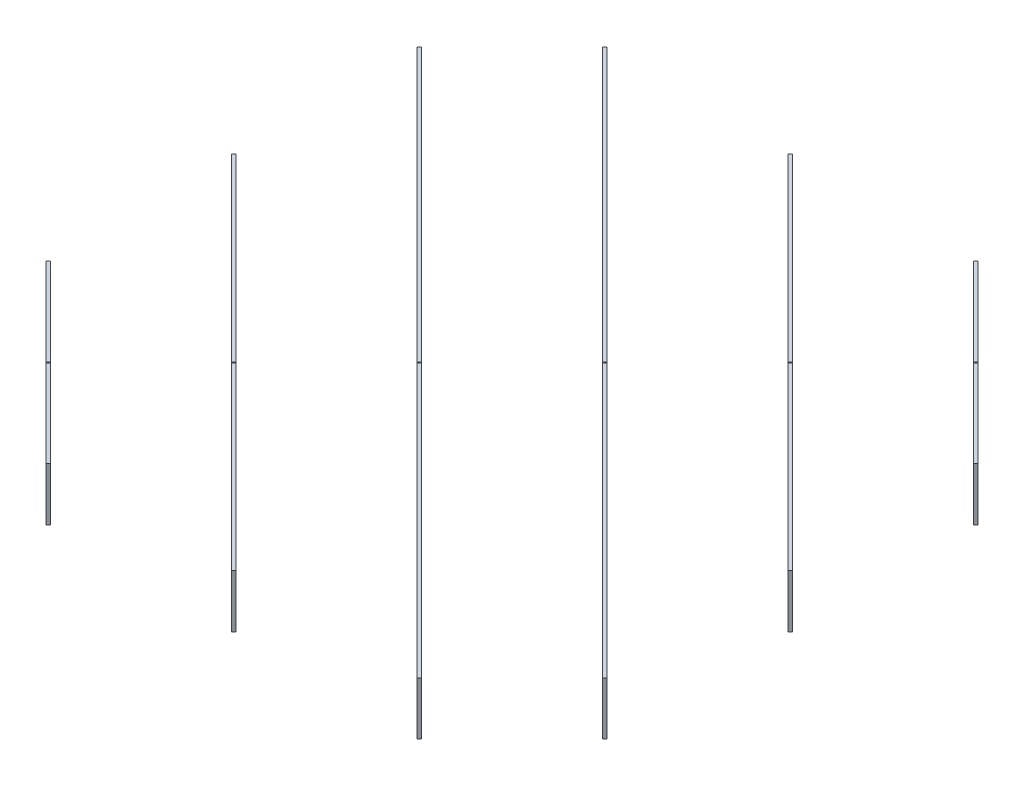
from build123d import *

# Parameters (mm, degrees)
BOSS_EXTRUDE1_DEPTH   = 100
BOSS_EXTRUDE1_2_DEPTH = 100
BOSS_EXTRUDE1_3_DEPTH = 100
BOSS_EXTRUDE1_4_DEPTH = 100
BOSS_EXTRUDE1_5_DEPTH = 100
BOSS_EXTRUDE1_6_DEPTH = 100
SKETCH3_R             = 1.5
SKETCH3_W             = 6
SKETCH3_H             = 100
CUT_EXTRUDE1_DEPTH    = 1478.317638774
SKETCH4_W             = 56
SKETCH4_H             = 12
CUT_EXTRUDE2_DEPTH    = 6
SKETCH5_W             = 56
SKETCH5_H             = 12
CUT_EXTRUDE3_DEPTH    = 6
SKETCH6_R             = 1.5
CUT_EXTRUDE4_DEPTH    = 1478.317638774
CUT_EXTRUDE5_START    = -253.487374
SKETCH7_R             = 4
CUT_EXTRUDE5_DEPTH    = 253.487374
CUT_EXTRUDE6_START    = -253.487374
SKETCH8_R             = 3
CUT_EXTRUDE6_DEPTH    = 253.487374
CUT_EXTRUDE7_START    = -253.487374
SKETCH9_R             = 3
CUT_EXTRUDE7_DEPTH    = 253.487374
SKETCH10_R            = 3
CUT_EXTRUDE8_DEPTH    = 748.46212
CUT_EXTRUDE9_START    = -253.487374
SKETCH11_R            = 3
CUT_EXTRUDE9_DEPTH    = 253.487374


with BuildPart() as part:
    # Sketch2 → Boss-Extrude1 (new body)
    with BuildSketch(Plane(origin=(0, 0, 0), x_dir=(1, 0, 0), z_dir=(0, 1, 0))):
        Polygon((-605, -274.242640687), (-274.242640687, -605), (-270, -600.757359313), (-600.757359313, -270), align=None)
    extrude(amount=BOSS_EXTRUDE1_DEPTH)


with BuildPart() as body_2:
    # Sketch2 → Boss-Extrude1 2 (new body)
    with BuildSketch(Plane(origin=(0, 0, 0), x_dir=(1, 0, 0), z_dir=(0, 1, 0))):
        Polygon((-605, 75.757359313), (75.757359313, -605), (80, -600.757359313), (-600.757359313, 80), align=None)
    extrude(amount=BOSS_EXTRUDE1_2_DEPTH)


with BuildPart() as body_3:
    # Sketch2 → Boss-Extrude1 3 (new body)
    with BuildSketch(Plane(origin=(0, 0, 0), x_dir=(1, 0, 0), z_dir=(0, 1, 0))):
        Polygon((-605, 425.757359313), (425.757359313, -605), (430, -600.757359313), (-600.757359313, 430), align=None)
    extrude(amount=BOSS_EXTRUDE1_3_DEPTH)


with BuildPart() as body_4:
    # Sketch2 → Boss-Extrude1 4 (new body)
    with BuildSketch(Plane(origin=(0, 0, 0), x_dir=(1, 0, 0), z_dir=(0, 1, 0))):
        Polygon((-430, 600.757359313), (600.757359313, -430), (605, -425.757359313), (-425.757359313, 605), align=None)
    extrude(amount=BOSS_EXTRUDE1_4_DEPTH)


with BuildPart() as body_5:
    # Sketch2 → Boss-Extrude1 5 (new body)
    with BuildSketch(Plane(origin=(0, 0, 0), x_dir=(1, 0, 0), z_dir=(0, 1, 0))):
        Polygon((-80, 600.757359313), (600.757359313, -80), (605, -75.757359313), (-75.757359313, 605), align=None)
    extrude(amount=BOSS_EXTRUDE1_5_DEPTH)


with BuildPart() as body_6:
    # Sketch2 → Boss-Extrude1 6 (new body)
    with BuildSketch(Plane(origin=(0, 0, 0), x_dir=(1, 0, 0), z_dir=(0, 1, 0))):
        Polygon((270, 600.757359313), (600.757359313, 270), (605, 274.242640687), (274.242640687, 605), align=None)
    extrude(amount=BOSS_EXTRUDE1_6_DEPTH)


with BuildPart() as cut_extrude1_tool:
    # Sketch3 → Cut-Extrude1 (new body, through all)
    with BuildSketch(Plane(origin=(-439.621320344, 0, 439.621320344), x_dir=(0.707106781, 0, 0.707106781), z_dir=(-0.707106781, 0, 0.707106781))):
        with Locations((-615.718433538, 50)):
            Circle(SKETCH3_R)
        with Locations((-621.718433538, 50)):
            Circle(SKETCH3_R)
        with Locations((-618.718433538, 0)):
            Rectangle(SKETCH3_W, SKETCH3_H)
        with BuildLine():
            Line((-621.718433538, 48.5), (-621.718433538, 50))
            Line((-621.718433538, 50), (-620.218433538, 50))
            ThreePointArc((-620.218433538, 50), (-622.77909371, 51.060660172), (-621.718433538, 48.5))
        make_face()
        with BuildLine():
            Line((-620.218433538, 50), (-621.718433538, 50))
            Line((-621.718433538, 50), (-621.718433538, 48.5))
            ThreePointArc((-621.718433538, 48.5), (-620.657773366, 48.939339828), (-620.218433538, 50))
        make_face()
        with BuildLine():
            ThreePointArc((-614.218433538, 50), (-615.718433538, 51.5), (-617.218433538, 50))
            Line((-617.218433538, 50), (-615.718433538, 50))
            Line((-615.718433538, 50), (-615.718433538, 48.5))
            ThreePointArc((-615.718433538, 48.5), (-614.657773366, 48.939339828), (-614.218433538, 50))
        make_face()
        with BuildLine():
            Line((-615.718433538, 50), (-617.218433538, 50))
            ThreePointArc((-617.218433538, 50), (-616.77909371, 48.939339828), (-615.718433538, 48.5))
            Line((-615.718433538, 48.5), (-615.718433538, 50))
        make_face()
        with BuildLine():
            Line((-374.231060123, 48.5), (-374.231060123, 50))
            Line((-374.231060123, 50), (-372.731060123, 50))
            ThreePointArc((-372.731060123, 50), (-375.291720295, 51.060660172), (-374.231060123, 48.5))
        make_face()
        with BuildLine():
            Line((-372.731060123, 50), (-374.231060123, 50))
            Line((-374.231060123, 50), (-374.231060123, 48.5))
            ThreePointArc((-374.231060123, 48.5), (-373.170399951, 48.939339828), (-372.731060123, 50))
        make_face()
        with Locations((-368.231060123, 50)):
            Circle(SKETCH3_R)
        with Locations((-374.231060123, 50)):
            Circle(SKETCH3_R)
        with Locations((-371.231060123, 0)):
            Rectangle(SKETCH3_W, SKETCH3_H)
        with BuildLine():
            ThreePointArc((-366.731060123, 50), (-368.231060123, 51.5), (-369.731060123, 50))
            Line((-369.731060123, 50), (-368.231060123, 50))
            Line((-368.231060123, 50), (-368.231060123, 48.5))
            ThreePointArc((-368.231060123, 48.5), (-367.170399951, 48.939339828), (-366.731060123, 50))
        make_face()
        with BuildLine():
            Line((-368.231060123, 50), (-369.731060123, 50))
            ThreePointArc((-369.731060123, 50), (-369.291720295, 48.939339828), (-368.231060123, 48.5))
            Line((-368.231060123, 48.5), (-368.231060123, 50))
        make_face()
        with BuildLine():
            Line((-126.705577884, 48.5), (-126.705577884, 50))
            Line((-126.705577884, 50), (-125.205577884, 50))
            ThreePointArc((-125.205577884, 50), (-127.766238056, 51.060660172), (-126.705577884, 48.5))
        make_face()
        with BuildLine():
            Line((-125.205577884, 50), (-126.705577884, 50))
            Line((-126.705577884, 50), (-126.705577884, 48.5))
            ThreePointArc((-126.705577884, 48.5), (-125.644917713, 48.939339828), (-125.205577884, 50))
        make_face()
        with BuildLine():
            ThreePointArc((-119.205577884, 50), (-120.705577884, 51.5), (-122.205577884, 50))
            Line((-122.205577884, 50), (-120.705577884, 50))
            Line((-120.705577884, 50), (-120.705577884, 48.5))
            ThreePointArc((-120.705577884, 48.5), (-119.644917713, 48.939339828), (-119.205577884, 50))
        make_face()
        with BuildLine():
            Line((-120.705577884, 50), (-122.205577884, 50))
            ThreePointArc((-122.205577884, 50), (-121.766238056, 48.939339828), (-120.705577884, 48.5))
            Line((-120.705577884, 48.5), (-120.705577884, 50))
        make_face()
        with BuildLine():
            Line((-122.205577884, 50), (-125.205577884, 50))
            ThreePointArc((-125.205577884, 50), (-125.644917713, 48.939339828), (-126.705577884, 48.5))
            Line((-126.705577884, 48.5), (-126.705577884, 0))
            Line((-126.705577884, 0), (-120.705577884, 0))
            Line((-120.705577884, 0), (-120.705577884, 48.5))
            ThreePointArc((-120.705577884, 48.5), (-121.766238056, 48.939339828), (-122.205577884, 50))
        make_face()
        with BuildLine():
            ThreePointArc((122.205577884, 50), (119.644917713, 51.060660172), (120.705577884, 48.5))
            Line((120.705577884, 48.5), (120.705577884, 50))
            Line((120.705577884, 50), (122.205577884, 50))
        make_face()
        with BuildLine():
            Line((120.705577884, 50), (120.705577884, 48.5))
            ThreePointArc((120.705577884, 48.5), (121.766238056, 48.939339828), (122.205577884, 50))
            Line((122.205577884, 50), (120.705577884, 50))
        make_face()
        with BuildLine():
            Line((120.705577884, 48.5), (120.705577884, 0))
            Line((120.705577884, 0), (126.705577884, 0))
            Line((126.705577884, 0), (126.705577884, 48.5))
            ThreePointArc((126.705577884, 48.5), (125.644917713, 48.939339828), (125.205577884, 50))
            Line((125.205577884, 50), (122.205577884, 50))
            ThreePointArc((122.205577884, 50), (121.766238056, 48.939339828), (120.705577884, 48.5))
        make_face()
        with BuildLine():
            ThreePointArc((125.205577884, 50), (125.644917713, 48.939339828), (126.705577884, 48.5))
            Line((126.705577884, 48.5), (126.705577884, 50))
            Line((126.705577884, 50), (125.205577884, 50))
        make_face()
        with BuildLine():
            Line((126.705577884, 50), (126.705577884, 48.5))
            ThreePointArc((126.705577884, 48.5), (127.766238056, 48.939339828), (128.205577884, 50))
            ThreePointArc((128.205577884, 50), (126.705577884, 51.5), (125.205577884, 50))
            Line((125.205577884, 50), (126.705577884, 50))
        make_face()
        with BuildLine():
            Line((369.731060123, 50), (368.231060123, 50))
            Line((368.231060123, 50), (368.231060123, 48.5))
            ThreePointArc((368.231060123, 48.5), (369.291720295, 48.939339828), (369.731060123, 50))
        make_face()
        with BuildLine():
            Line((368.231060123, 48.5), (368.231060123, 50))
            Line((368.231060123, 50), (369.731060123, 50))
            ThreePointArc((369.731060123, 50), (367.170399951, 51.060660172), (368.231060123, 48.5))
        make_face()
        with Locations((374.231060123, 50)):
            Circle(SKETCH3_R)
        with Locations((368.231060123, 50)):
            Circle(SKETCH3_R)
        with Locations((371.231060123, 0)):
            Rectangle(SKETCH3_W, SKETCH3_H)
        with BuildLine():
            ThreePointArc((375.731060123, 50), (374.231060123, 51.5), (372.731060123, 50))
            Line((372.731060123, 50), (374.231060123, 50))
            Line((374.231060123, 50), (374.231060123, 48.5))
            ThreePointArc((374.231060123, 48.5), (375.291720295, 48.939339828), (375.731060123, 50))
        make_face()
        with BuildLine():
            Line((374.231060123, 50), (372.731060123, 50))
            ThreePointArc((372.731060123, 50), (373.170399951, 48.939339828), (374.231060123, 48.5))
            Line((374.231060123, 48.5), (374.231060123, 50))
        make_face()
        with BuildLine():
            Line((617.218433538, 50), (615.718433538, 50))
            Line((615.718433538, 50), (615.718433538, 48.5))
            ThreePointArc((615.718433538, 48.5), (616.77909371, 48.939339828), (617.218433538, 50))
        make_face()
        with BuildLine():
            Line((615.718433538, 48.5), (615.718433538, 50))
            Line((615.718433538, 50), (617.218433538, 50))
            ThreePointArc((617.218433538, 50), (614.657773366, 51.060660172), (615.718433538, 48.5))
        make_face()
        with BuildLine():
            ThreePointArc((623.218433538, 50), (621.718433538, 51.5), (620.218433538, 50))
            Line((620.218433538, 50), (621.718433538, 50))
            Line((621.718433538, 50), (621.718433538, 48.5))
            ThreePointArc((621.718433538, 48.5), (622.77909371, 48.939339828), (623.218433538, 50))
        make_face()
        with BuildLine():
            Line((621.718433538, 50), (620.218433538, 50))
            ThreePointArc((620.218433538, 50), (620.657773366, 48.939339828), (621.718433538, 48.5))
            Line((621.718433538, 48.5), (621.718433538, 50))
        make_face()
        with Locations((621.718433538, 50)):
            Circle(SKETCH3_R)
        with Locations((615.718433538, 50)):
            Circle(SKETCH3_R)
        with Locations((618.718433538, 0)):
            Rectangle(SKETCH3_W, SKETCH3_H)
    extrude(amount=-CUT_EXTRUDE1_DEPTH)


with BuildPart() as part_1:
    add(part.part)

    # Cut-Extrude1: cut by cut_extrude1_tool
    add(cut_extrude1_tool.part, mode=Mode.SUBTRACT)


with BuildPart() as body_2_1:
    add(body_2.part)

    # Cut-Extrude1: cut by cut_extrude1_tool
    add(cut_extrude1_tool.part, mode=Mode.SUBTRACT)

    # Sketch5 → Cut-Extrude3 (cut)
    with BuildSketch(Plane(origin=(-264.621320344, 0, 264.621320344), x_dir=(0.707106781, 0, 0.707106781), z_dir=(-0.707106781, 0, 0.707106781))):
        with Locations((0.019054412, 22)):
            Rectangle(SKETCH5_W, SKETCH5_H)
    extrude(amount=-CUT_EXTRUDE3_DEPTH, mode=Mode.SUBTRACT)


with BuildPart() as body_3_1:
    add(body_3.part)

    # Cut-Extrude1: cut by cut_extrude1_tool
    add(cut_extrude1_tool.part, mode=Mode.SUBTRACT)


with BuildPart() as body_4_1:
    add(body_4.part)

    # Cut-Extrude1: cut by cut_extrude1_tool
    add(cut_extrude1_tool.part, mode=Mode.SUBTRACT)


with BuildPart() as body_5_1:
    add(body_5.part)

    # Cut-Extrude1: cut by cut_extrude1_tool
    add(cut_extrude1_tool.part, mode=Mode.SUBTRACT)

    # Sketch4 → Cut-Extrude2 (cut)
    with BuildSketch(Plane(origin=(260.378679656, 0, -260.378679656), x_dir=(0.707106781, 0, 0.707106781), z_dir=(-0.707106781, 0, 0.707106781))):
        with Locations((0.019054412, 22)):
            Rectangle(SKETCH4_W, SKETCH4_H)
    extrude(amount=-CUT_EXTRUDE2_DEPTH, mode=Mode.SUBTRACT)


with BuildPart() as body_6_1:
    add(body_6.part)

    # Cut-Extrude1: cut by cut_extrude1_tool
    add(cut_extrude1_tool.part, mode=Mode.SUBTRACT)


with BuildPart() as cut_extrude4_tool:
    # Sketch6 → Cut-Extrude4 (new body, through all)
    with BuildSketch(Plane(origin=(-439.621320344, 0, 439.621320344), x_dir=(0.707106781, 0, 0.707106781), z_dir=(-0.707106781, 0, 0.707106781))):
        with Locations((0, 100)):
            Circle(SKETCH6_R)
    extrude(amount=-CUT_EXTRUDE4_DEPTH)


with BuildPart() as part_2:
    add(part_1.part)

    # Cut-Extrude4: cut by cut_extrude4_tool
    add(cut_extrude4_tool.part, mode=Mode.SUBTRACT)


with BuildPart() as body_2_2:
    add(body_2_1.part)

    # Cut-Extrude4: cut by cut_extrude4_tool
    add(cut_extrude4_tool.part, mode=Mode.SUBTRACT)


with BuildPart() as body_3_2:
    add(body_3_1.part)

    # Cut-Extrude4: cut by cut_extrude4_tool
    add(cut_extrude4_tool.part, mode=Mode.SUBTRACT)


with BuildPart() as body_4_2:
    add(body_4_1.part)

    # Cut-Extrude4: cut by cut_extrude4_tool
    add(cut_extrude4_tool.part, mode=Mode.SUBTRACT)


with BuildPart() as body_5_2:
    add(body_5_1.part)

    # Cut-Extrude4: cut by cut_extrude4_tool
    add(cut_extrude4_tool.part, mode=Mode.SUBTRACT)


with BuildPart() as body_6_2:
    add(body_6_1.part)

    # Cut-Extrude4: cut by cut_extrude4_tool
    add(cut_extrude4_tool.part, mode=Mode.SUBTRACT)


with BuildPart() as cut_extrude5_tool:
    # Sketch7 → Cut-Extrude5 (new body)
    with BuildSketch(Plane(origin=(-89.621320344, 0, 89.621320344), x_dir=(0.707106781, 0, 0.707106781), z_dir=(-0.707106781, 0, 0.707106781)).offset(CUT_EXTRUDE5_START)):
        with Locations((0, 84)):
            Circle(SKETCH7_R)
        with Locations((0, 64)):
            Circle(SKETCH7_R)
    extrude(amount=CUT_EXTRUDE5_DEPTH)


with BuildPart() as body_3_3:
    add(body_3_2.part)

    # Cut-Extrude5: cut by cut_extrude5_tool
    add(cut_extrude5_tool.part, mode=Mode.SUBTRACT)


with BuildPart() as body_4_3:
    add(body_4_2.part)

    # Cut-Extrude5: cut by cut_extrude5_tool
    add(cut_extrude5_tool.part, mode=Mode.SUBTRACT)


with BuildPart() as cut_extrude6_tool:
    # Sketch8 → Cut-Extrude6 (new body)
    with BuildSketch(Plane(origin=(-439.621320344, 0, 439.621320344), x_dir=(0.707106781, 0, 0.707106781), z_dir=(-0.707106781, 0, 0.707106781)).offset(CUT_EXTRUDE6_START)):
        with Locations((0, 50)):
            Circle(SKETCH8_R)
    extrude(amount=CUT_EXTRUDE6_DEPTH)


with BuildPart() as part_3:
    add(part_2.part)

    # Cut-Extrude6: cut by cut_extrude6_tool
    add(cut_extrude6_tool.part, mode=Mode.SUBTRACT)


with BuildPart() as body_2_3:
    add(body_2_2.part)

    # Cut-Extrude6: cut by cut_extrude6_tool
    add(cut_extrude6_tool.part, mode=Mode.SUBTRACT)


with BuildPart() as cut_extrude7_tool:
    # Sketch9 → Cut-Extrude7 (new body)
    with BuildSketch(Plane(origin=(439.621320344, 0, -439.621320344), x_dir=(-0.707106781, 0, -0.707106781), z_dir=(0.707106781, 0, -0.707106781)).offset(CUT_EXTRUDE7_START)):
        with Locations((0, 50)):
            Circle(SKETCH9_R)
    extrude(amount=CUT_EXTRUDE7_DEPTH)


with BuildPart() as body_5_3:
    add(body_5_2.part)

    # Cut-Extrude7: cut by cut_extrude7_tool
    add(cut_extrude7_tool.part, mode=Mode.SUBTRACT)


with BuildPart() as body_6_3:
    add(body_6_2.part)

    # Cut-Extrude7: cut by cut_extrude7_tool
    add(cut_extrude7_tool.part, mode=Mode.SUBTRACT)


with BuildPart() as cut_extrude8_tool:
    # Sketch10 → Cut-Extrude8 (new body)
    with BuildSketch(Plane(origin=(-264.621320344, 0, 264.621320344), x_dir=(0.707106781, 0, 0.707106781), z_dir=(-0.707106781, 0, 0.707106781))):
        with Locations((-247.477846209, 50)):
            Circle(SKETCH10_R)
    cut_extrude8 = extrude(amount=-CUT_EXTRUDE8_DEPTH)


with BuildPart() as body_2_4:
    add(body_2_3.part)

    # Cut-Extrude8: cut by cut_extrude8_tool
    add(cut_extrude8_tool.part, mode=Mode.SUBTRACT)


with BuildPart() as body_3_4:
    add(body_3_3.part)

    # Cut-Extrude8: cut by cut_extrude8_tool
    add(cut_extrude8_tool.part, mode=Mode.SUBTRACT)


with BuildPart() as body_4_4:
    add(body_4_3.part)

    # Cut-Extrude8: cut by cut_extrude8_tool
    add(cut_extrude8_tool.part, mode=Mode.SUBTRACT)


with BuildPart() as body_5_4:
    add(body_5_3.part)

    # Cut-Extrude8: cut by cut_extrude8_tool
    add(cut_extrude8_tool.part, mode=Mode.SUBTRACT)


with BuildPart() as cut_extrude9_tool:
    # Sketch11 → Cut-Extrude9 (new body)
    with BuildSketch(Plane(origin=(-89.621320344, 0, 89.621320344), x_dir=(0.707106781, 0, 0.707106781), z_dir=(-0.707106781, 0, 0.707106781)).offset(CUT_EXTRUDE9_START)):
        with Locations((-494.974746831, 50)):
            Circle(SKETCH11_R)
    cut_extrude9 = extrude(amount=CUT_EXTRUDE9_DEPTH)


with BuildPart() as body_3_5:
    add(body_3_4.part)

    # Cut-Extrude9: cut by cut_extrude9_tool
    add(cut_extrude9_tool.part, mode=Mode.SUBTRACT)


with BuildPart() as body_4_5:
    add(body_4_4.part)

    # Cut-Extrude9: cut by cut_extrude9_tool
    add(cut_extrude9_tool.part, mode=Mode.SUBTRACT)


with BuildPart() as mirror1_tool:
    # Mirror1: Cut-Extrude8, Cut-Extrude9 across plane
    add(cut_extrude8.mirror(Plane(origin=(0, 0, 0), x_dir=(-0.707106781, 0, 0.707106781), z_dir=(-0.707106781, 0, -0.707106781))))
    add(cut_extrude9.mirror(Plane(origin=(0, 0, 0), x_dir=(-0.707106781, 0, 0.707106781), z_dir=(-0.707106781, 0, -0.707106781))))


with BuildPart() as body_2_5:
    add(body_2_4.part)

    # Mirror1: cut by mirror1_tool
    add(mirror1_tool.part, mode=Mode.SUBTRACT)


with BuildPart() as body_3_6:
    add(body_3_5.part)

    # Mirror1: cut by mirror1_tool
    add(mirror1_tool.part, mode=Mode.SUBTRACT)


with BuildPart() as body_4_6:
    add(body_4_5.part)

    # Mirror1: cut by mirror1_tool
    add(mirror1_tool.part, mode=Mode.SUBTRACT)


with BuildPart() as body_5_5:
    add(body_5_4.part)

    # Mirror1: cut by mirror1_tool
    add(mirror1_tool.part, mode=Mode.SUBTRACT)


solid = Compound([part_3.part, body_6_3.part, body_2_5.part, body_3_6.part, body_4_6.part, body_5_5.part])
